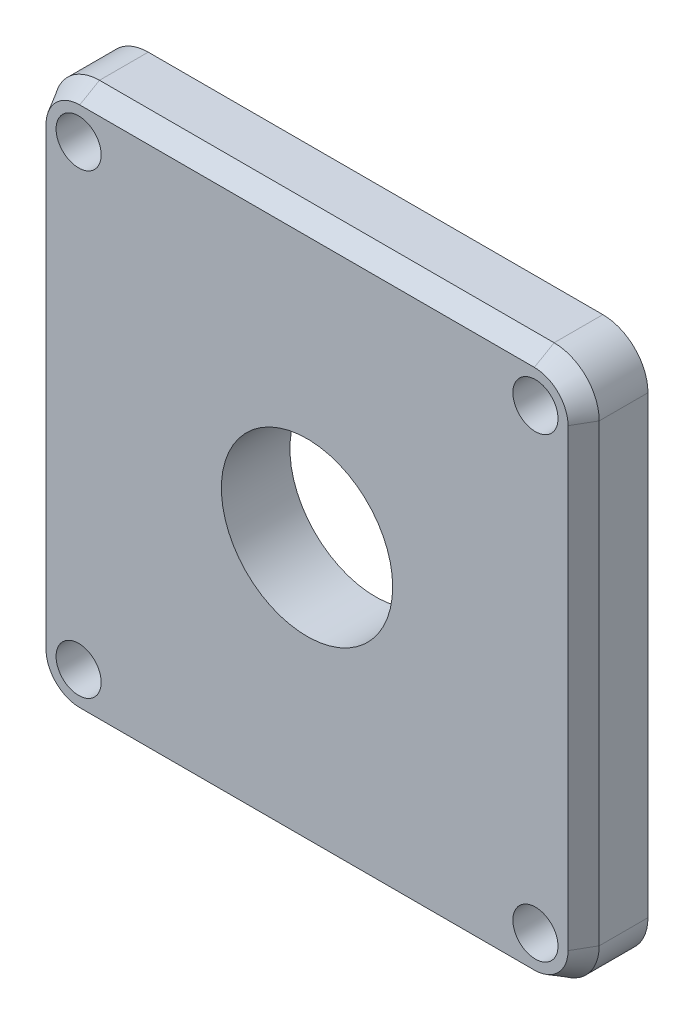
from build123d import *

# Parameters (mm, degrees)
ESQUISSE1_W             = 95.41492783
ESQUISSE1_H             = 95.41492783
ESQUISSE1_R             = 3.95
ESQUISSE1_R_2           = 15
BOSS_EXTRU_1_DEPTH      = 2
BOSS_EXTRU_2_START      = 2
ESQUISSE1_3_W           = 95.41492783
ESQUISSE1_3_H           = 95.41492783
ESQUISSE1_3_R           = 15
ESQUISSE1_3_R_2         = 3.95
BOSS_EXTRU_2_DEPTH      = 10
CONG_1_R                = 7.9
CHANFREIN1_SIZE         = 2
CHANFREIN1_SIZE2        = 3.464101615
ESQUISSE4_R             = 3.15
ENL_V_MAT_EXTRU_2_DEPTH = 8


with BuildPart() as part:
    # Esquisse1 → Boss.-Extru.1 (new body)
    with BuildSketch(Plane.XY):
        Rectangle(ESQUISSE1_W, ESQUISSE1_H)
        with Locations((-40, -40)):
            Circle(ESQUISSE1_R, mode=Mode.SUBTRACT)
        with Locations((40, -40)):
            Circle(ESQUISSE1_R, mode=Mode.SUBTRACT)
        with Locations((40, 40)):
            Circle(ESQUISSE1_R, mode=Mode.SUBTRACT)
        with Locations((-40, 40)):
            Circle(ESQUISSE1_R, mode=Mode.SUBTRACT)
        Circle(ESQUISSE1_R_2, mode=Mode.SUBTRACT)
        with Locations((-40, -40)):
            Circle(ESQUISSE1_R)
        with Locations((40, -40)):
            Circle(ESQUISSE1_R)
        with Locations((40, 40)):
            Circle(ESQUISSE1_R)
        with Locations((-40, 40)):
            Circle(ESQUISSE1_R)
    extrude(amount=BOSS_EXTRU_1_DEPTH)

    # Esquisse1_3 → Boss.-Extru.2 (add)
    with BuildSketch(Plane.XY.offset(BOSS_EXTRU_2_START)):
        Rectangle(ESQUISSE1_3_W, ESQUISSE1_3_H)
        Circle(ESQUISSE1_3_R, mode=Mode.SUBTRACT)
        with Locations((-40, 40)):
            Circle(ESQUISSE1_3_R_2, mode=Mode.SUBTRACT)
        with Locations((40, 40)):
            Circle(ESQUISSE1_3_R_2, mode=Mode.SUBTRACT)
        with Locations((40, -40)):
            Circle(ESQUISSE1_3_R_2, mode=Mode.SUBTRACT)
        with Locations((-40, -40)):
            Circle(ESQUISSE1_3_R_2, mode=Mode.SUBTRACT)
    extrude(amount=BOSS_EXTRU_2_DEPTH)

    # Congé1
    cong_1_edges = [part.edges().sort_by_distance(p)[0] for p in [
        (-47.707463915, -47.707463915, 6),
        (-47.707463915, 47.707463915, 6),
        (47.707463915, 47.707463915, 6),
        (47.707463915, -47.707463915, 6),
    ]]
    fillet(cong_1_edges, radius=CONG_1_R)

    # Chanfrein1
    chanfrein1_edges = [part.edges().sort_by_distance(p)[0] for p in [
        (0, 47.707463915, 12),
        (47.707463915, 0, 12),
        (-47.707463915, 0, 12),
        (0, -47.707463915, 12),
        (-45.393607486, 45.393607486, 12),
        (-45.393607486, -45.393607486, 12),
        (45.393607486, -45.393607486, 12),
        (45.393607486, 45.393607486, 12),
    ]]
    chanfrein1_side = [part.faces().sort_by_distance(p)[0] for p in [
        (0, -46.358093065, 12),
    ]]
    chamfer(chanfrein1_edges, length=CHANFREIN1_SIZE, length2=CHANFREIN1_SIZE2, reference=chanfrein1_side[0])

    # Esquisse4 → Enlèv. mat.-Extru.2 (cut)
    with BuildSketch(Plane(origin=(0, 0, 0), x_dir=(-1, 0, 0), z_dir=(0, 0, -1))):
        with Locations((-30, 30)):
            Circle(ESQUISSE4_R)
        with Locations((-30, -30)):
            Circle(ESQUISSE4_R)
        with Locations((30, -30)):
            Circle(ESQUISSE4_R)
        with Locations((30, 30)):
            Circle(ESQUISSE4_R)
    extrude(amount=-ENL_V_MAT_EXTRU_2_DEPTH, mode=Mode.SUBTRACT)


solid = part.part
